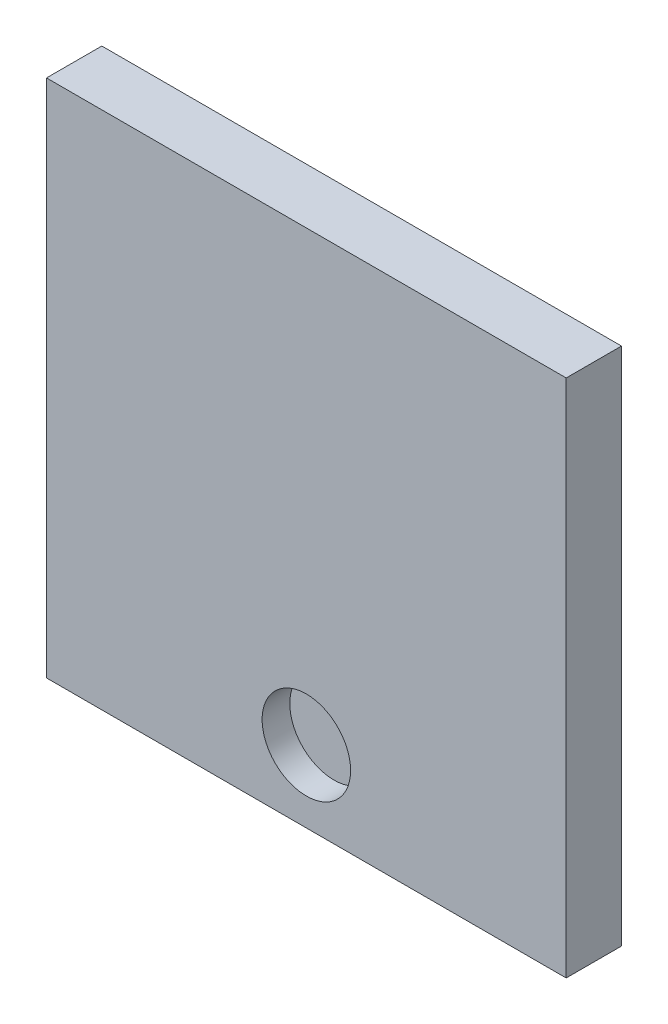
from build123d import *

# Parameters (mm, degrees)
SCHIZZO1_W                   = 94
SCHIZZO1_H                   = 94
ESTRUSIONE_ESTRUSIONE1_DEPTH = 10
SCHIZZO3_R                   = 8
TAGLIO_ESTRUSIONE1_DEPTH     = 5


with BuildPart() as part:
    # Schizzo1 → Estrusione-Estrusione1 (new body)
    with BuildSketch(Plane.XY):
        Rectangle(SCHIZZO1_W, SCHIZZO1_H)
    extrude(amount=ESTRUSIONE_ESTRUSIONE1_DEPTH)

    # Schizzo3 → Taglio-Estrusione1 (cut)
    with BuildSketch(Plane.XY.offset(10)):
        with Locations((0, -34)):
            Circle(SCHIZZO3_R)
    extrude(amount=-TAGLIO_ESTRUSIONE1_DEPTH, mode=Mode.SUBTRACT)


solid = part.part
